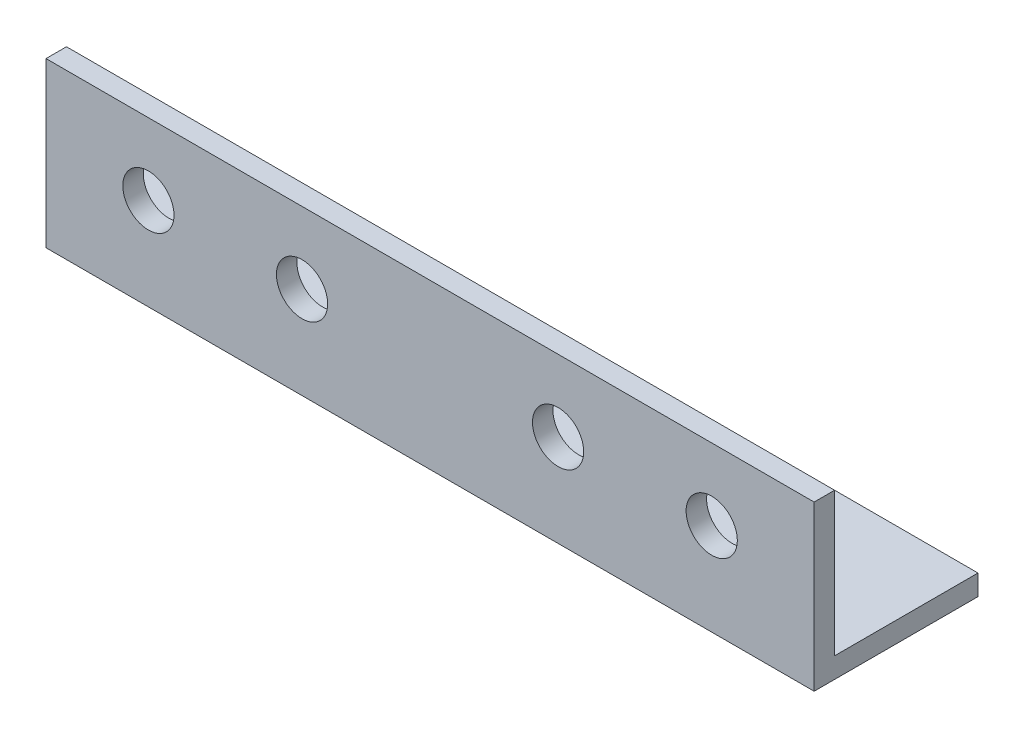
from build123d import *

# Parameters (mm, degrees)
EXTRUDE_1_DEPTH     = 150
SKETCH_2_R          = 5
CUT_EXTRUDE_1_DEPTH = 5


with BuildPart() as part:
    # Эскиз1 → Вытянуть-Тонкостенный1 (new body)
    with BuildSketch(Plane(origin=(0, 0, 0), x_dir=(0, 0, -1), z_dir=(1, 0, 0))):
        Polygon((0, 32), (0, 0), (32, 0), (32, 4), (4, 4), (4, 32), align=None)
    extrude(amount=EXTRUDE_1_DEPTH)

    # Эскиз2 → Вырез-Вытянуть1 (cut, through all)
    with BuildSketch(Plane(origin=(0, 0, -4), x_dir=(-1, 0, 0), z_dir=(0, 0, -1))):
        with Locations((-130, 18)):
            Circle(SKETCH_2_R)
        with Locations((-100, 18)):
            Circle(SKETCH_2_R)
        with Locations((-50, 18)):
            Circle(SKETCH_2_R)
        with Locations((-20, 18)):
            Circle(SKETCH_2_R)
    extrude(amount=-CUT_EXTRUDE_1_DEPTH, mode=Mode.SUBTRACT)


solid = part.part
